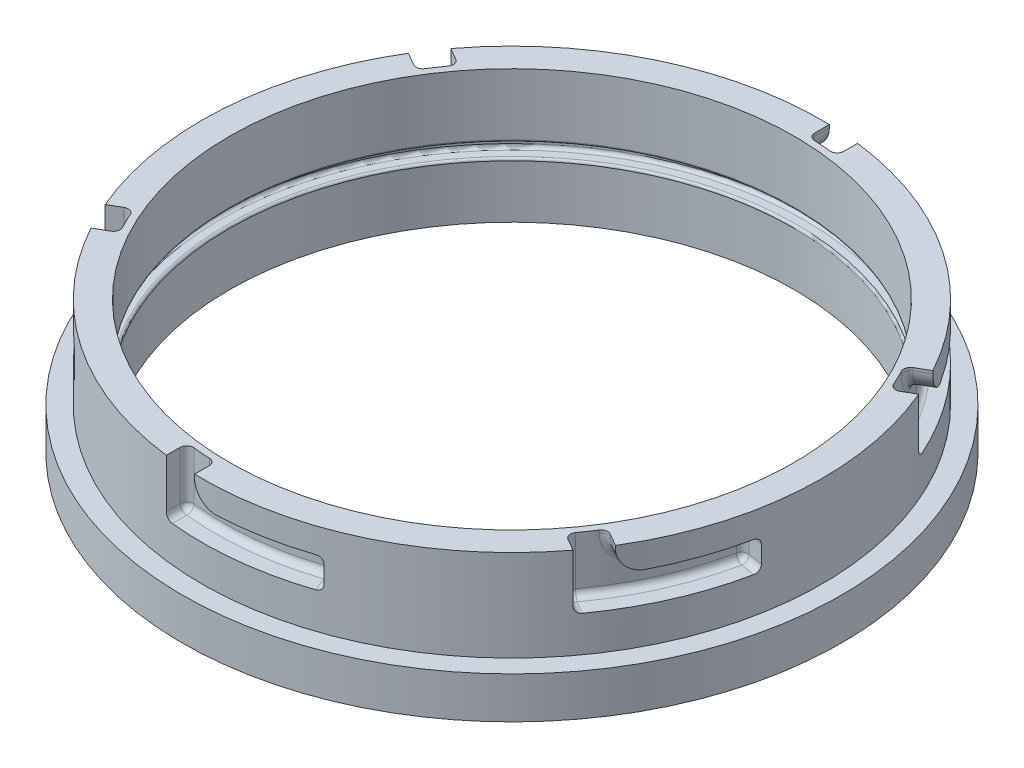
from build123d import *

# Parameters (mm, degrees)
CUT_EXTRUDE1_START       = -12.7
CUT_EXTRUDE1_DEPTH       = 12.7
SKETCH10_W               = 4.827435186195032
SKETCH10_H               = 6.9850000000000065
FILLET1_R                = 5.08
FILLET4_R                = 1.524
CIRPATTERN1_COUNT        = 6
FILLET1_OF_CIRPATTERN1_R = 5.08
FILLET4_OF_CIRPATTERN1_R = 1.524
FILLET2_R                = 0.762
FILLET3_R                = 0.508


with BuildPart() as part:
    # Sketch1 → Revolve1 (revolve)
    with BuildSketch(Plane.XY):
        Polygon((71.11999999999999, 36.51250000000001), (71.11999999999999, 15.557500000000015), (75.56500000000001, 15.557500000000017), (75.565, 6.032500000000017), (64.77000000000001, 6.032500000000014), (64.77000000000001, 18.732500000000012), (67.81799999999998, 18.732500000000012), (67.81799999999998, 21.907500000000017), (64.77, 21.907500000000013), (64.77, 36.51250000000001), align=None)
    revolve(axis=Axis((0, 60.75795454545431, 0), (1.2e-16, -1, 0)))

    # Sketch2 → Cut-Extrude1 (cut)
    with BuildSketch(Plane(origin=(-4.47e-15, 36.5125, 0), x_dir=(1, 1.2e-16, 0), z_dir=(-1.2e-16, 1, 0)).offset(CUT_EXTRUDE1_START)):
        with BuildLine():
            Line((-8.659215820595662, -70.59088029889091), (-8.659215820595662, -65.7260406336206))
            ThreePointArc((-8.659215820595662, -65.7260406336206), (-5.173944735082208, -66.09179020028368), (-1.6742158205956637, -66.27285596219667))
            Line((-1.6742158205956637, -66.27285596219667), (-1.6742158205956637, -71.1002911483917))
            ThreePointArc((-1.6742158205956637, -71.1002911483917), (-5.172990162777308, -70.93161899164441), (-8.659215820595662, -70.59088029889091))
        make_face()
    cut_extrude1 = extrude(amount=CUT_EXTRUDE1_DEPTH, mode=Mode.SUBTRACT)

    # Cut-Sweep2: sweep along a path in Sketch23
    with BuildLine(Plane(origin=(-2.92e-15, 23.812500000000004, 0), x_dir=(1, 1.2e-16, 0), z_dir=(-1.2e-16, 1, 0))) as cut_sweep2_path:
        ThreePointArc((-1.6742158205956639, -71.1002911483917), (11.313422517678514, -70.21439219231685), (23.92201927626626, -66.97605089691348))
    # Sketch10 → Cut-Sweep2 (sweep, cut)
    with BuildSketch(Plane.ZY.offset(1.6742158205956639)):
        with Locations((68.68657355529419, 27.305000000000003)):
            Rectangle(SKETCH10_W, SKETCH10_H)
    cut_sweep2 = sweep(path=cut_sweep2_path.line, mode=Mode.SUBTRACT)

    # Fillet1
    fillet1_edges = [part.edges().sort_by_distance(p)[0] for p in [
        (-1.6742158205956676, 30.797500000000007, 68.68657355529419),
    ]]
    fillet(fillet1_edges, radius=FILLET1_R)

    # Fillet4
    fillet4_edges = [part.edges().sort_by_distance(p)[0] for p in [
        (-1.6742158205956668, 36.19500000000001, 66.27285596219667),
        (-0.18582286684972082, 32.284902176794, 66.29373957046366),
        (23.05685308016756, 30.797500000000007, 64.72271557513899),
        (-8.659215820595666, 23.812500000000004, 68.15846046625575),
        (23.05685308016756, 23.812500000000004, 64.72271557513899),
        (-8.659215820595668, 30.1625, 65.7260406336206),
        (12.934414118168412, 30.797500000000007, 65.01996129974029),
        (6.95941107271422, 23.812500000000004, 65.92769549681668),
        (22.191686884068872, 27.305000000000007, 62.46938025336449),
    ]]
    fillet(fillet4_edges, radius=FILLET4_R)

    # CirPattern1: Cut-Extrude1, Cut-Sweep2 ×6 about axis
    cirpattern1_axis = Axis((0, 60.75795454545431, 0), (-1.2e-16, 1, 0))
    add([cut_extrude1.rotate(cirpattern1_axis, i * 360 / CIRPATTERN1_COUNT) for i in range(1, CIRPATTERN1_COUNT)], mode=Mode.SUBTRACT)
    add([cut_sweep2.rotate(cirpattern1_axis, i * 360 / CIRPATTERN1_COUNT) for i in range(1, CIRPATTERN1_COUNT)], mode=Mode.SUBTRACT)

    # Fillet1 of CirPattern1
    fillet1_of_cirpattern1_edges = [part.edges().sort_by_distance(p)[0] for p in [
        (58.64720968749536, 30.797500000000014, 35.793200209700764),
        (60.321425508091046, 30.797500000000014, -32.89337334559342),
        (1.6742158205956834, 30.797500000000007, -68.68657355529419),
        (-58.647209687495334, 30.7975, -35.793200209700785),
        (-60.321425508091025, 30.7975, 32.89337334559344),
    ]]
    fillet(fillet1_of_cirpattern1_edges, radius=FILLET1_OF_CIRPATTERN1_R)

    # Fillet4 of CirPattern1
    fillet4_of_cirpattern1_edges = [part.edges().sort_by_distance(p)[0] for p in [
        (56.55686893431148, 36.195000000000014, 34.586341413152006),
        (57.31915114646635, 32.284902176794006, 33.30779710852775),
        (67.5799424300689, 30.797500000000014, 12.39353728881892),
        (54.697350336316994, 23.81250000000001, 41.57833111061584),
        (67.5799424300689, 23.81250000000001, 12.393537288818921),
        (52.590812968585865, 30.16250000000001, 40.362121194298275),
        (62.776145297740364, 30.797500000000014, 21.308449440468213),
        (60.574764649565296, 23.81250000000001, 26.936820964059127),
        (65.19591370011806, 27.30500000000001, 12.016125532248683),
        (58.23108475490716, 36.195000000000014, -31.68651454904466),
        (57.50497401331608, 32.284902176794006, -32.9859424619359),
        (44.52308934990136, 30.79750000000001, -52.329178286320065),
        (63.35656615691267, 23.81250000000001, -26.580129355639894),
        (44.52308934990136, 23.812500000000007, -52.329178286320065),
        (61.25002878918154, 30.16250000000001, -25.36391943932232),
        (49.841731179571966, 30.79750000000001, -43.71151185927207),
        (53.615353576851085, 23.81250000000001, -38.990874532757545),
        (43.004226816049204, 27.30500000000001, -50.453254721115805),
        (1.674215820595681, 36.19500000000001, -66.27285596219667),
        (0.18582286684973592, 32.284902176794, -66.29373957046366),
        (-23.056853080167546, 30.7975, -64.72271557513899),
        (8.659215820595682, 23.812500000000007, -68.15846046625575),
        (-23.056853080167542, 23.812499999999996, -64.72271557513899),
        (8.659215820595682, 30.162500000000005, -65.7260406336206),
        (-12.934414118168398, 30.797500000000003, -65.01996129974029),
        (-6.959411072714202, 23.812500000000004, -65.92769549681668),
        (-22.191686884068858, 27.305, -62.46938025336449),
        (-56.55686893431146, 36.195, -34.58634141315203),
        (-57.319151146466325, 32.28490217679399, -33.30779710852777),
        (-67.57994243006888, 30.797499999999996, -12.393537288818944),
        (-54.697350336316966, 23.812499999999996, -41.57833111061586),
        (-67.57994243006888, 23.812499999999993, -12.393537288818946),
        (-52.59081296858584, 30.162499999999994, -40.36212119429829),
        (-62.77614529774034, 30.797499999999996, -21.308449440468237),
        (-60.57476464956527, 23.812499999999996, -26.93682096405915),
        (-65.19591370011804, 27.304999999999996, -12.016125532248708),
        (-58.231084754907144, 36.195, 31.686514549044684),
        (-57.50497401331606, 32.28490217679399, 32.98594246193592),
        (-44.52308934990133, 30.7975, 52.32917828632009),
        (-63.356566156912656, 23.812499999999996, 26.580129355639915),
        (-44.52308934990133, 23.812499999999996, 52.32917828632009),
        (-61.25002878918153, 30.162499999999994, 25.36391943932234),
        (-49.841731179571944, 30.7975, 43.711511859272086),
        (-53.615353576851064, 23.812499999999996, 38.990874532757566),
        (-43.004226816049176, 27.305, 50.45325472111582),
    ]]
    fillet(fillet4_of_cirpattern1_edges, radius=FILLET4_OF_CIRPATTERN1_R)

    # Fillet2
    fillet2_edges = [part.edges().sort_by_distance(p)[0] for p in [
        (-67.81799999999998, 21.9075, 8.31e-15),
        (-67.81799999999998, 18.7325, 8.31e-15),
    ]]
    fillet(fillet2_edges, radius=FILLET2_R)

    # Fillet3
    fillet3_edges = [part.edges().sort_by_distance(p)[0] for p in [
        (-64.77000000000001, 18.7325, 7.93e-15),
        (-64.77, 21.9075, 7.93e-15),
    ]]
    fillet(fillet3_edges, radius=FILLET3_R)


solid = part.part
